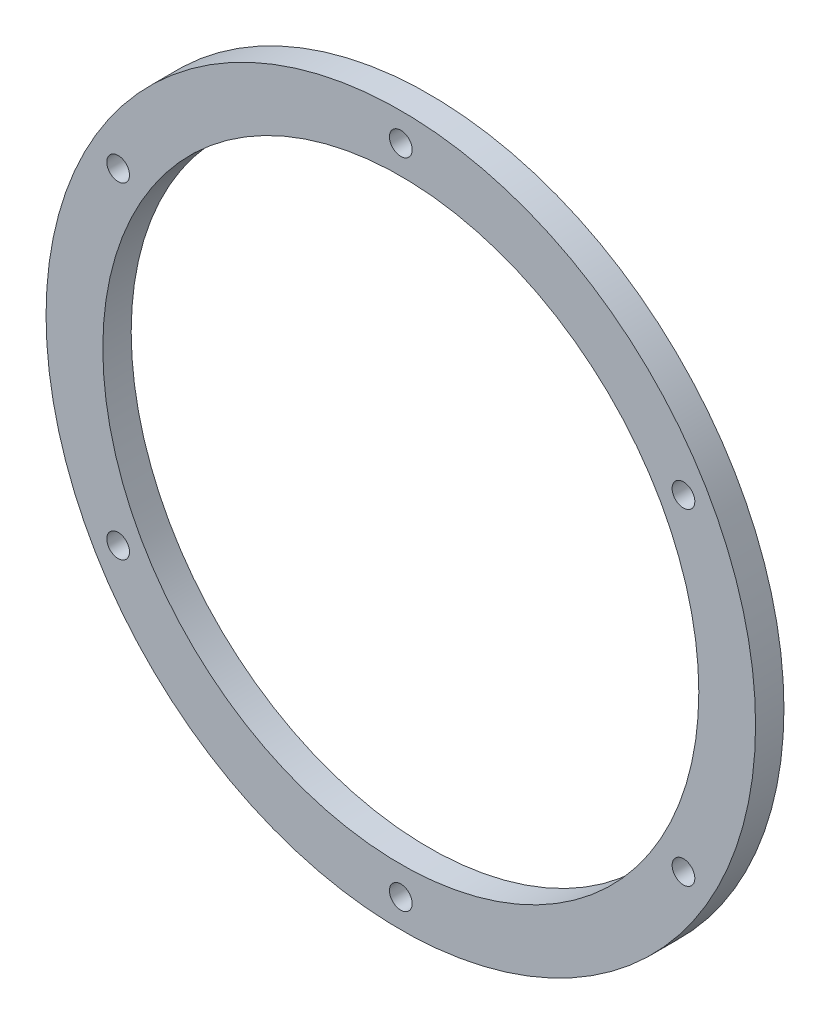
from build123d import *

# Parameters (mm, degrees)
SKETCH1_R          = 125
SKETCH1_R_2        = 105
BODY_DEPTH         = 5
SKETCH2_R          = 4
CUT_EXTRUDE1_DEPTH = 11
HOLES_COUNT        = 6


with BuildPart() as part:
    # Sketch1 → Body (new body, symmetric)
    with BuildSketch(Plane.XY):
        Circle(SKETCH1_R)
        Circle(SKETCH1_R_2, mode=Mode.SUBTRACT)
    extrude(amount=BODY_DEPTH, both=True)

    # Sketch2 → Cut-Extrude1 (cut, through all)
    with BuildSketch(Plane.XY.offset(5)):
        with Locations((0, 115)):
            Circle(SKETCH2_R)
    cut_extrude1 = extrude(amount=-CUT_EXTRUDE1_DEPTH, mode=Mode.SUBTRACT)

    # Holes: Cut-Extrude1 ×6 about axis
    holes_axis = Axis((0, 0, 0), (0, 0, 1))
    for i in range(1, HOLES_COUNT):
        add(cut_extrude1.rotate(holes_axis, i * 360 / HOLES_COUNT), mode=Mode.SUBTRACT)


solid = part.part
